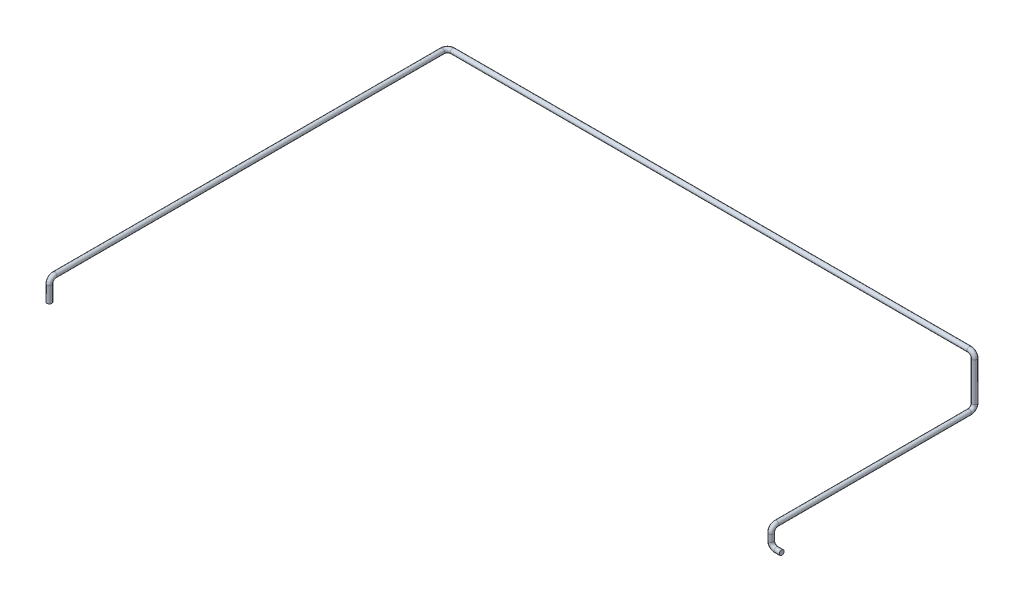
from build123d import *

# Parameters (mm, degrees)
CROQUIS1_R = 13.7


with BuildPart() as part:
    # Barrer1: sweep along a curve in space
    with BuildLine() as barrer1_path:
        Line((0, 0, 0), (-30, 0, 0))
        ThreePointArc((-30, 0, 0), (-51.213203436, 8.786796564, 0), (-60, 30, 0))
        Line((-60, 30, 0), (-60, 70, 0))
        ThreePointArc((-60, 70, 0), (-60, 91.213203436, -8.786796564), (-60, 100, -30))
        Line((-60, 100, -30), (-60, 100, -1130))
        ThreePointArc((-60, 130, -1160), (-60, 108.786796564, -1151.213203436), (-60, 100, -1130))
        Line((-60, 130, -1160), (-60, 350, -1160))
        ThreePointArc((-60, 350, -1160), (-68.786796564, 371.213203436, -1160), (-90, 380, -1160))
        Line((-90, 380, -1160), (-3035, 380, -1160))
        ThreePointArc((-3035, 380, -1160), (-3056.213203436, 380, -1151.213203436), (-3065, 380, -1130))
        Line((-3065, 380, -1130), (-3065, 380, 1080))
        ThreePointArc((-3065, 380, 1080), (-3065, 371.213203436, 1101.213203436), (-3065, 350, 1110))
        Line((-3065, 350, 1110), (-3065, 260, 1110))
    # Croquis1 → Barrer1 (sweep)
    with BuildSketch(Plane(origin=(0, 0, 0), x_dir=(0, 0, -1), z_dir=(1, 0, 0))):
        Circle(CROQUIS1_R)
    sweep(path=barrer1_path.line)


solid = part.part
